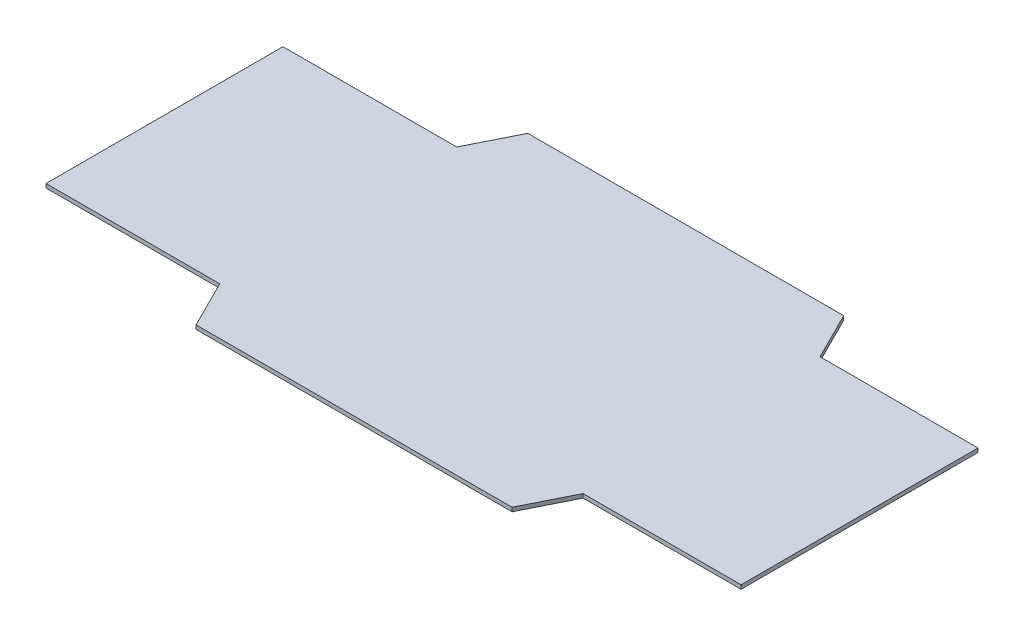
from build123d import *

# Parameters (mm, degrees)
BOSS_EXTRUDE1_DEPTH = 1.5875


with BuildPart() as part:
    # Sketch3 → Boss-Extrude1 (new body, symmetric)
    with BuildSketch(Plane(origin=(0, 0, 0), x_dir=(1, 0, 0), z_dir=(0, 1, 0))):
        Polygon((-279.4, 95.25), (-139.7, 95.25), (-120.65, 133.35), (133.35, 133.35), (152.4, 95.25), (279.4, 95.25), (279.4, -95.25), (152.4, -95.25), (133.35, -133.35), (-120.65, -133.35), (-139.7, -95.25), (-279.4, -95.25), align=None)
    extrude(amount=BOSS_EXTRUDE1_DEPTH, both=True)


solid = part.part
